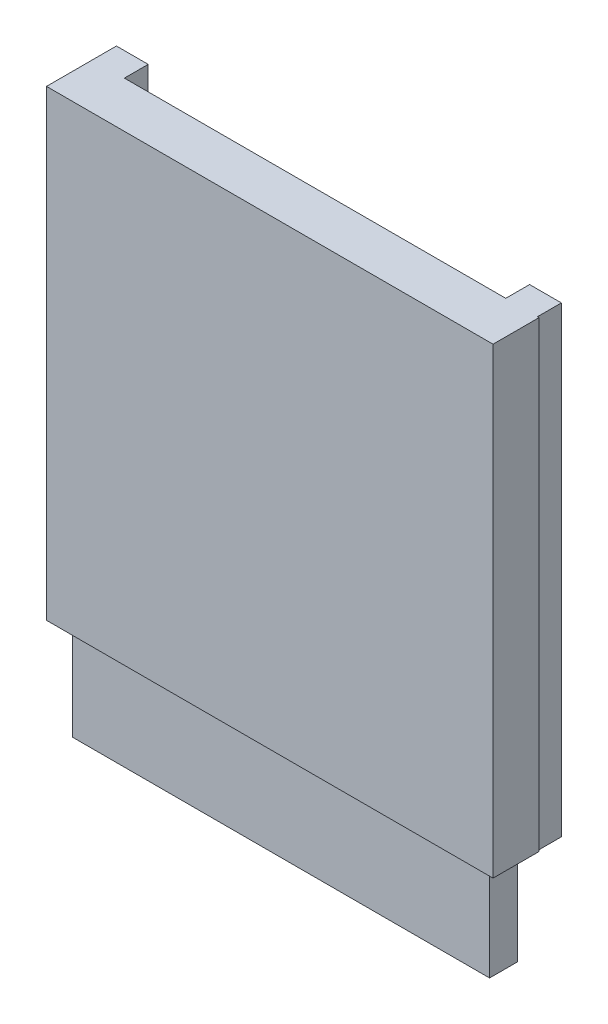
from build123d import *

# Parameters (mm, degrees)
SKETCH1_R          = 0.5
EXTRUDE1_DEPTH     = 0.508
EXTRUDE1_2_DEPTH   = 0.508
SKETCH2_W          = 2
SKETCH2_H          = 29.1
EXTRUDE2_DEPTH     = 1.5
SKETCH3_W          = 28.1
SKETCH3_H          = 29.1
EXTRUDE3_DEPTH     = 2.9
SKETCH4_W          = 27.082087072
SKETCH4_H          = 2.272405007
CUT_EXTRUDE1_DEPTH = 26.3
SKETCH5_W          = 26.233061925
SKETCH5_H          = 1.7432148
EXTRUDE4_DEPTH     = 32.5


with BuildPart() as part:
    # Sketch1 → Extrude1 (new body)
    with BuildSketch(Plane.XY):
        Circle(SKETCH1_R)
    extrude(amount=-EXTRUDE1_DEPTH)



with BuildPart() as body_2:
    # Sketch1 → Extrude1 2 (new body)
    with BuildSketch(Plane.XY):
        with Locations((26, 0)):
            Circle(SKETCH1_R)
    extrude(amount=-EXTRUDE1_2_DEPTH)


with BuildPart() as part_1:
    add(part.part)

    add(body_2.part)  # Extrude2 merges body 2
    # Sketch2 → Extrude2 (add)
    with BuildSketch(Plane.XY):
        with Locations((0, -11.75)):
            Rectangle(SKETCH2_W, SKETCH2_H)
        with Locations((26, -11.75)):
            Rectangle(SKETCH2_W, SKETCH2_H)
    extrude(amount=EXTRUDE2_DEPTH)

    # Sketch3 → Extrude3 (add)
    with BuildSketch(Plane.XY.offset(1.5)):
        with Locations((13.05, -11.75)):
            Rectangle(SKETCH3_W, SKETCH3_H)
    extrude(amount=EXTRUDE3_DEPTH)

    # Sketch4 → Cut-Extrude1 (cut)
    with BuildSketch(Plane.XZ.offset(26.3)):
        with Locations((13.034435582, 2.89542949)):
            Rectangle(SKETCH4_W, SKETCH4_H)
    extrude(amount=-CUT_EXTRUDE1_DEPTH, mode=Mode.SUBTRACT)

    # Sketch5 → Extrude4 (add)
    with BuildSketch(Plane.XZ):
        with Locations((13.116530963, 2.879865071)):
            Rectangle(SKETCH5_W, SKETCH5_H)
    extrude(amount=EXTRUDE4_DEPTH)


solid = part_1.part
